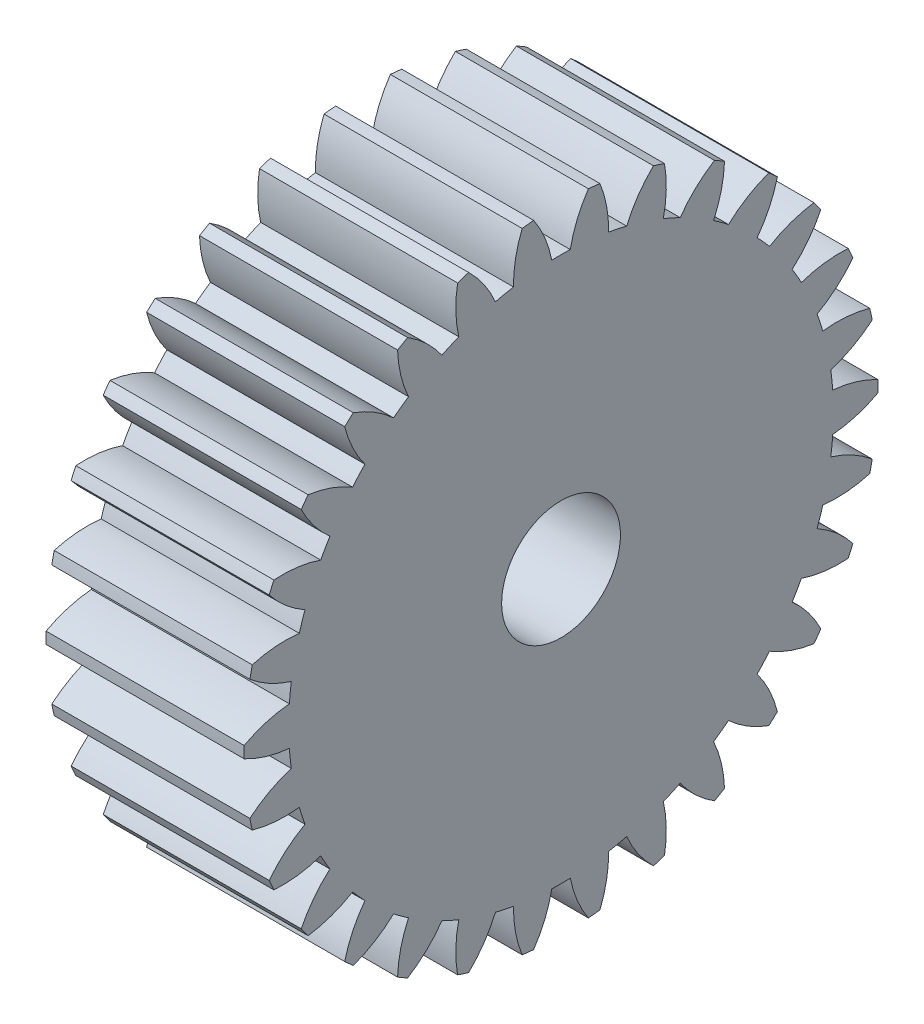
from build123d import *

# Parameters (mm, degrees)
BASPROSKE_W        = 10
BASPROSKE_H        = 16
TOOTHCUT_DEPTH     = 25.738633754
TEETHCUTS_COUNT    = 30
TEETHCUTS_ANGLE    = 348
HUBNEAONESKE_R     = 12.5
HUBNEARONE_DEPTH   = 8.0000508
BORSKE_R           = 3
BORE_DEPTH         = 18.0000508
SKETCH1_R          = 12.5
CUT_EXTRUDE1_DEPTH = 8.0000508


with BuildPart() as part:
    # BasProSke → Base-Revolve (revolve)
    with BuildSketch(Plane(origin=(0, 0, 0), x_dir=(1, 0, 0), z_dir=(0, 1, 0)), mode=Mode.PRIVATE) as base_revolve_sk:
        with Locations((5, 8)):
            Rectangle(BASPROSKE_W, BASPROSKE_H)
    revolve(base_revolve_sk.sketch.rotate(Axis((-10, 0, 0), (1, 0, 0)), 180), axis=Axis((-10, 0, 0), (1, 0, 0)))

    # TooCutSke → ToothCut (cut, through all)
    with BuildSketch(Plane(origin=(0, 0, 0), x_dir=(0, 0, -1), z_dir=(1, 0, 0))):
        with BuildLine():
            ThreePointArc((0.466400716, 13.741086979), (0, 13.749), (-0.466400716, 13.741086979))
            ThreePointArc((-0.466400716, 13.741086979), (-0.819142092, 14.899954875), (-1.3974676, 15.964351834))
            ThreePointArc((-1.3974676, 15.964351834), (0, 16.0254), (1.3974676, 15.964351834))
            ThreePointArc((1.3974676, 15.964351834), (0.819142092, 14.899954875), (0.466400716, 13.741086979))
        make_face()
    toothcut = extrude(amount=TOOTHCUT_DEPTH, mode=Mode.SUBTRACT)

    # TeethCuts: ToothCut ×30 about axis
    teethcuts_axis = Axis((-10, 0, 0), (1, 0, 0))
    for i in range(1, TEETHCUTS_COUNT):
        add(toothcut.rotate(teethcuts_axis, i * TEETHCUTS_ANGLE / (TEETHCUTS_COUNT - 1)), mode=Mode.SUBTRACT)

    # HubNeaOneSke → HubNearOne (add)
    with BuildSketch(Plane.ZY):
        with Locations(Location((0, 0, 0), (0, 0, 180))):
            Circle(HUBNEAONESKE_R)
    extrude(amount=HUBNEARONE_DEPTH)

    # BorSke → Bore (cut, symmetric)
    with BuildSketch(Plane(origin=(0, 0, 0), x_dir=(0, 0, -1), z_dir=(1, 0, 0))):
        with Locations(Location((0, 0, 0), (0, 0, 180))):
            Circle(BORSKE_R)
    extrude(amount=BORE_DEPTH, both=True, mode=Mode.SUBTRACT)

    # Sketch1 → Cut-Extrude1 (cut)
    with BuildSketch(Plane.ZY.offset(8.0000508)):
        Circle(SKETCH1_R)
    extrude(amount=-CUT_EXTRUDE1_DEPTH, mode=Mode.SUBTRACT)


solid = part.part
